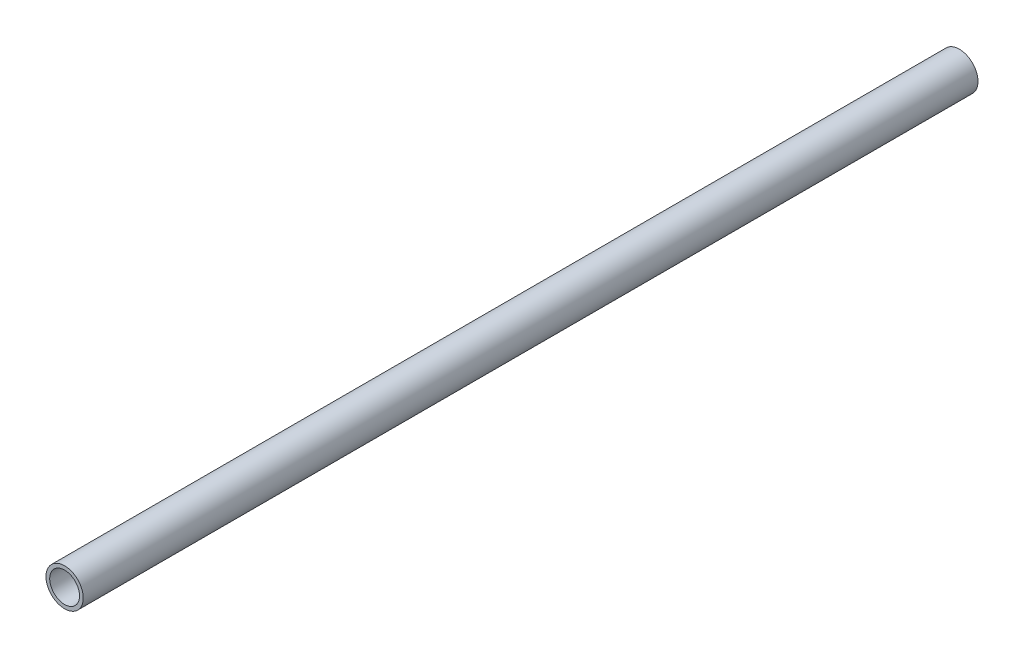
from build123d import *

# Parameters (mm, degrees)
SKETCH1_R           = 12.7
SKETCH1_R_2         = 10.16
BOSS_EXTRUDE1_DEPTH = 609.6


with BuildPart() as part:
    # Sketch1 → Boss-Extrude1 (new body)
    with BuildSketch(Plane.XY):
        Circle(SKETCH1_R)
        Circle(SKETCH1_R_2, mode=Mode.SUBTRACT)
    extrude(amount=BOSS_EXTRUDE1_DEPTH)


solid = part.part
